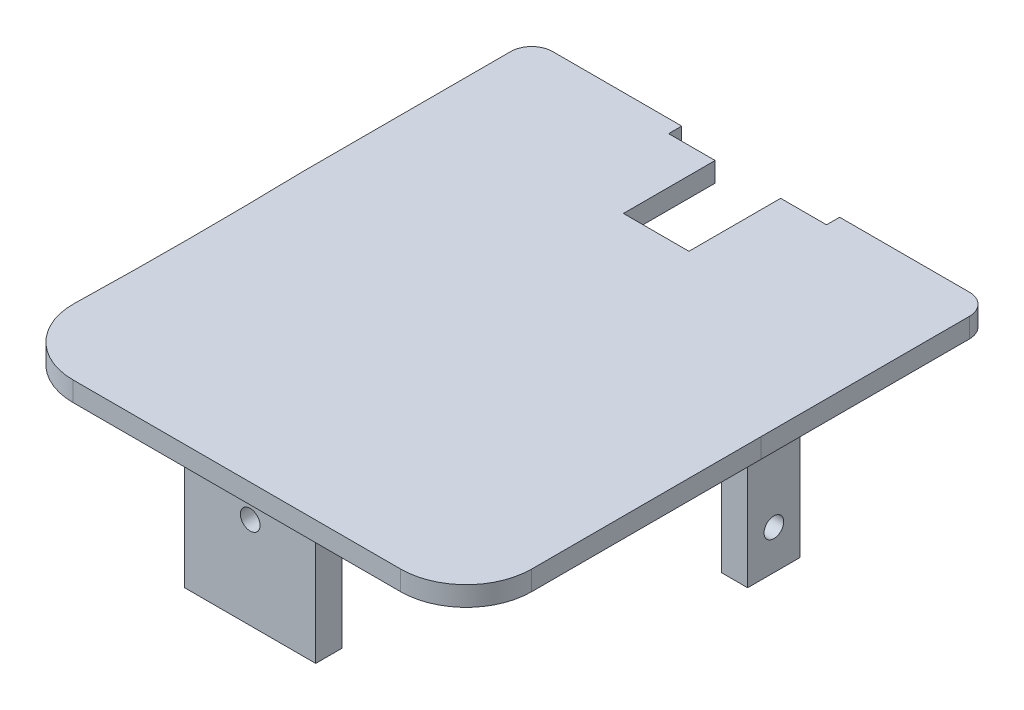
from build123d import *

# Parameters (mm, degrees)
BOSS_EXTRUDE4_DEPTH    = 0.75
EXTRUDE_THIN2_DEPTH    = 0.75
UPPER_17_W             = 5
UPPER_17_H             = 1
UPPER_17_W_2           = 1
UPPER_17_H_2           = 2
LID_ANCHOR_FRONT_DEPTH = 4.5
TAP_LATERAL_LID_D      = 0.75
TAP_FRONT_LID_D        = 0.75
CUT_EXTRUDE1_REACH     = 16.029


with BuildPart() as part:
    # upper_13 → Boss-Extrude4 (new body)
    with BuildSketch(Plane(origin=(0, -19, 0), x_dir=(1, 0, 0), z_dir=(0, 1, 0))):
        with BuildLine():
            Line((-6.250353693, -9.5), (6.250353693, -9.5))
            ThreePointArc((6.250353693, -9.5), (7.665029054, -8.913751613), (8.250353267, -7.498693623))
            ThreePointArc((8.250353267, -7.498693623), (8.248836313, -3.124346866), (8.25, 1.25))
            Line((8.25, 1.25), (8.25, 9.2))
            ThreePointArc((8.25, 9.2), (8.162132034, 9.412132034), (7.95, 9.5))
            Line((7.95, 9.5), (1.25, 9.5))
            Line((1.25, 9.5), (1.25, 6))
            Line((1.25, 6), (-1.25, 6))
            Line((-1.25, 6), (-1.25, 9.5))
            Line((-1.25, 9.5), (-7.95, 9.5))
            ThreePointArc((-7.95, 9.5), (-8.162132034, 9.412132034), (-8.25, 9.2))
            Line((-8.25, 9.2), (-8.25, 1.25))
            ThreePointArc((-8.25, 1.25), (-8.199296345, -3.106194095), (-8.25, -7.462388189))
            ThreePointArc((-8.25, -7.462388189), (-7.677803101, -8.900852665), (-6.250353693, -9.5))
        make_face()
    extrude(amount=BOSS_EXTRUDE4_DEPTH)



with BuildPart() as body_2:
    # upper_16 → Extrude-Thin2 (new body)
    with BuildSketch(Plane(origin=(0, -19, 0), x_dir=(1, 0, 0), z_dir=(0, 1, 0))):
        with BuildLine():
            Line((-8.75, 1.244176388), (-8.75, 9.2))
            ThreePointArc((-8.75, 9.2), (-8.515685425, 9.765685425), (-7.95, 10))
            Line((-7.95, 10), (7.95, 10))
            ThreePointArc((7.95, 10), (8.515685425, 9.765685425), (8.75, 9.2))
            Line((8.75, 9.2), (8.75, 1.24985689))
            ThreePointArc((8.75, 1.24985689), (8.74883631, -3.124255124), (8.75035316, -7.498367029))
            ThreePointArc((8.75035316, -7.498367029), (8.018697895, -9.267189516), (6.250353693, -10))
            Line((6.250353693, -10), (-6.250353693, -10))
            ThreePointArc((-6.250353693, -10), (-8.035078913, -9.250644422), (-8.749889093, -7.451804713))
            ThreePointArc((-8.749889093, -7.451804713), (-8.69929636, -3.103813517), (-8.75, 1.244176388))
        make_face()
        with BuildLine():
            Line((-8.25, 1.25), (-8.25, 9.2))
            ThreePointArc((-8.25, 9.2), (-8.162132034, 9.412132034), (-7.95, 9.5))
            Line((-7.95, 9.5), (7.95, 9.5))
            ThreePointArc((7.95, 9.5), (8.162132034, 9.412132034), (8.25, 9.2))
            Line((8.25, 9.2), (8.25, 1.25))
            ThreePointArc((8.25, 1.25), (8.248836313, -3.124346866), (8.250353267, -7.498693623))
            ThreePointArc((8.250353267, -7.498693623), (7.665029054, -8.913751613), (6.250353693, -9.5))
            Line((6.250353693, -9.5), (-6.250353693, -9.5))
            ThreePointArc((-6.250353693, -9.5), (-7.677803101, -8.900852665), (-8.25, -7.462388189))
            ThreePointArc((-8.25, -7.462388189), (-8.199296345, -3.106194095), (-8.25, 1.25))
        make_face(mode=Mode.SUBTRACT)
    extrude(amount=EXTRUDE_THIN2_DEPTH)


with BuildPart() as part_1:
    add(part.part)

    add(body_2.part)  # lid_anchor_front merges body 2
    # upper_17 → lid_anchor_front (add)
    with BuildSketch(Plane(origin=(0, -19, 0), x_dir=(1, 0, 0), z_dir=(0, 1, 0))):
        with Locations((0, -8.99)):
            Rectangle(UPPER_17_W, UPPER_17_H)
        with Locations((-7.74, 2.25)):
            Rectangle(UPPER_17_W_2, UPPER_17_H_2)
    lid_anchor_front = extrude(amount=-LID_ANCHOR_FRONT_DEPTH)

    # tap_lateral_lid (through all)
    with Locations(Plane.ZY.offset(8.24)):
        with Locations((-2.25, -22)):
            tap_lateral_lid = Hole(TAP_LATERAL_LID_D / 2)

    # Mirror3: lid_anchor_front, tap_lateral_lid across plane
    add(lid_anchor_front.mirror(Plane(origin=(0, 0, 0), x_dir=(0, 0, 1), z_dir=(1, 0, 0))))
    add(tap_lateral_lid.mirror(Plane(origin=(0, 0, 0), x_dir=(0, 0, 1), z_dir=(1, 0, 0))), mode=Mode.SUBTRACT)

    # tap_front_lid (through all)
    with Locations(Plane.XY.offset(9.49)):
        with Locations((0, -20)):
            Hole(TAP_FRONT_LID_D / 2)

    # upper_18 → Cut-Extrude1 (cut, up to next)
    with BuildSketch(Plane(origin=(0, -19, 0), x_dir=(1, 0, 0), z_dir=(0, 1, 0)), mode=Mode.PRIVATE) as cut_extrude1_sk1:
        with BuildLine():
            ThreePointArc((-2.5, 9.5), (-1.767766953, 11.267766953), (0, 12))
            Line((0, 12), (-1.556624327, 12))
            Line((-1.556624327, 12), (-3, 9.5))
            Line((-3, 9.5), (-2.5, 9.5))
        make_face()
    cut_extrude1_tool1 = extrude(cut_extrude1_sk1.sketch, amount=CUT_EXTRUDE1_REACH, mode=Mode.PRIVATE) & part_1.part
    # upper_18 → Cut-Extrude1 (cut, up to next)
    with BuildSketch(Plane(origin=(0, -19, 0), x_dir=(1, 0, 0), z_dir=(0, 1, 0)), mode=Mode.PRIVATE) as cut_extrude1_sk2:
        with BuildLine():
            Line((2.5, 9.5), (3, 9.5))
            Line((3, 9.5), (1.556624327, 12))
            Line((1.556624327, 12), (0, 12))
            ThreePointArc((0, 12), (1.767766953, 11.267766953), (2.5, 9.5))
        make_face()
    cut_extrude1_tool2 = extrude(cut_extrude1_sk2.sketch, amount=CUT_EXTRUDE1_REACH, mode=Mode.PRIVATE) & part_1.part
    # upper_18 → Cut-Extrude1 (cut, up to next)
    with BuildSketch(Plane(origin=(0, -19, 0), x_dir=(1, 0, 0), z_dir=(0, 1, 0)), mode=Mode.PRIVATE) as cut_extrude1_sk3:
        with BuildLine():
            Line((1.25, 9.5), (2.5, 9.5))
            ThreePointArc((2.5, 9.5), (1.767766953, 11.267766953), (0, 12))
            ThreePointArc((0, 12), (-1.767766953, 11.267766953), (-2.5, 9.5))
            Line((-2.5, 9.5), (-1.25, 9.5))
            Line((-1.25, 9.5), (1.25, 9.5))
        make_face()
    cut_extrude1_tool3 = extrude(cut_extrude1_sk3.sketch, amount=CUT_EXTRUDE1_REACH, mode=Mode.PRIVATE) & part_1.part
    # upper_18 → Cut-Extrude1 (cut, up to next)
    with BuildSketch(Plane(origin=(0, -19, 0), x_dir=(1, 0, 0), z_dir=(0, 1, 0)), mode=Mode.PRIVATE) as cut_extrude1_sk4:
        Polygon((1.556624327, 12), (3, 9.5), (3, 12), align=None)
    cut_extrude1_tool4 = extrude(cut_extrude1_sk4.sketch, amount=CUT_EXTRUDE1_REACH, mode=Mode.PRIVATE) & part_1.part
    # upper_18 → Cut-Extrude1 (cut, up to next)
    with BuildSketch(Plane(origin=(0, -19, 0), x_dir=(1, 0, 0), z_dir=(0, 1, 0)), mode=Mode.PRIVATE) as cut_extrude1_sk5:
        Polygon((-3.025026025, 12), (-3.025026025, 9.5), (-3, 9.5), (-1.556624327, 12), align=None)
    cut_extrude1_tool5 = extrude(cut_extrude1_sk5.sketch, amount=CUT_EXTRUDE1_REACH, mode=Mode.PRIVATE) & part_1.part
    add(cut_extrude1_tool1.solids().sort_by_distance((-2.75, -19, -9.539051))[0], mode=Mode.SUBTRACT)
    add(cut_extrude1_tool2.solids().sort_by_distance((2.244493, -19, -10.730474))[0], mode=Mode.SUBTRACT)
    add(cut_extrude1_tool3.solids().sort_by_distance((0, -19, -10.561033))[0], mode=Mode.SUBTRACT)
    add(cut_extrude1_tool4.solids().sort_by_distance((2.518875, -19, -11.166667))[0], mode=Mode.SUBTRACT)
    add(cut_extrude1_tool5.solids().sort_by_distance((-2.535419, -19, -11.152702))[0], mode=Mode.SUBTRACT)


solid = part_1.part
